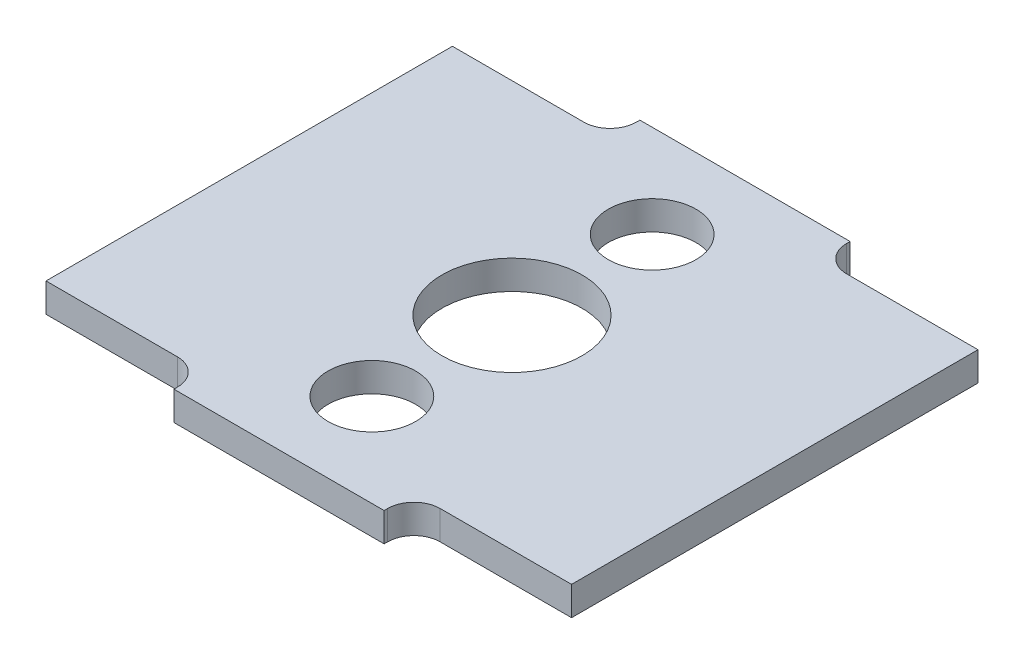
from build123d import *

# Parameters (mm, degrees)
SKIZZE1_R                       = 1.25
SKIZZE1_R_2                     = 5
AUFSATZ_LINEAR_AUSTRAGEN1_DEPTH = 0.825
VERRUNDUNG1_R                   = 1.5
SKIZZE3_R                       = 5
SKIZZE3_R_2                     = 4
AUFSATZ_LINEAR_AUSTRAGEN2_DEPTH = 1.65
SKIZZE4_R                       = 2.5
SCHNITT_LINEAR_AUSTRAGEN1_DEPTH = 2.65


with BuildPart() as part:
    # Skizze1 → Aufsatz-Linear austragen1 (new body, symmetric)
    with BuildSketch(Plane(origin=(0, 0, 0), x_dir=(1, 0, 0), z_dir=(0, 1, 0))):
        Polygon((-6, 11.6), (-6, 13.3), (6, 13.3), (6, 11.6), (15, 11.6), (15, -11.6), (6, -11.6), (6, -13.3), (-6, -13.3), (-6, -11.6), (-15, -11.6), (-15, 11.6), align=None)
        with Locations((0, -8)):
            Circle(SKIZZE1_R, mode=Mode.SUBTRACT)
        with Locations((0, 8)):
            Circle(SKIZZE1_R, mode=Mode.SUBTRACT)
        Circle(SKIZZE1_R_2, mode=Mode.SUBTRACT)
    extrude(amount=AUFSATZ_LINEAR_AUSTRAGEN1_DEPTH, both=True)

    # Verrundung1
    verrundung1_edges = [part.edges().sort_by_distance(p)[0] for p in [
        (-6, 0, 11.6),
        (-6, 0, -11.6),
        (6, 0, -11.6),
        (6, 0, 11.6),
    ]]
    fillet(verrundung1_edges, radius=VERRUNDUNG1_R)

    # Skizze3 → Aufsatz-Linear austragen2 (add)
    with BuildSketch(Plane(origin=(0, 0.825, 0), x_dir=(1, 0, 0), z_dir=(0, 1, 0))):
        Circle(SKIZZE3_R)
        Circle(SKIZZE3_R_2, mode=Mode.SUBTRACT)
    extrude(amount=-AUFSATZ_LINEAR_AUSTRAGEN2_DEPTH)

    # Skizze4 → Schnitt-Linear austragen1 (cut, through all)
    with BuildSketch(Plane(origin=(0, 0.825, 0), x_dir=(1, 0, 0), z_dir=(0, 1, 0))):
        with Locations((0, 8)):
            Circle(SKIZZE4_R)
        with Locations((0, -8)):
            Circle(SKIZZE4_R)
    extrude(amount=-SCHNITT_LINEAR_AUSTRAGEN1_DEPTH, mode=Mode.SUBTRACT)


solid = part.part
